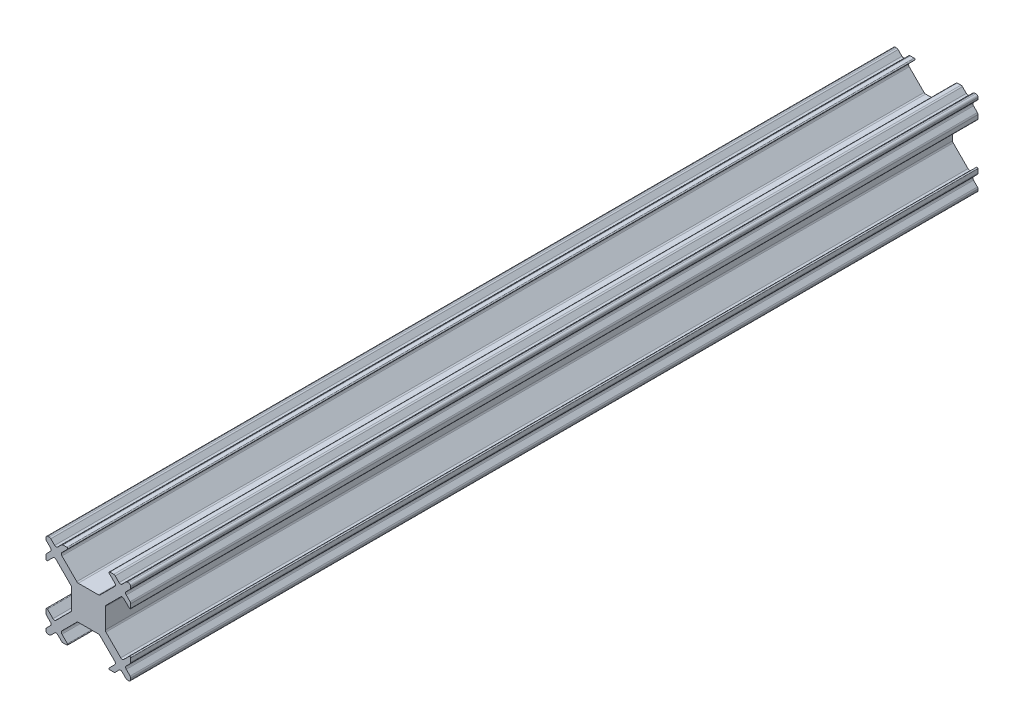
from build123d import *

# Parameters (mm, degrees)
BOSS_EXTRUDE1_DEPTH = 100


with BuildPart() as part:
    # Sketch1 → Boss-Extrude1 (new body)
    with BuildSketch(Plane.XY):
        with BuildLine():
            Line((-26.434620061, 28.496491655), (-25.979594809, 28.951516907))
            ThreePointArc((-25.979594809, 28.951516907), (-25.906371503, 29.128293603), (-25.979594808, 29.305070299))
            Line((-25.979594808, 29.305070299), (-26.43462006, 29.760095551))
            ThreePointArc((-26.43462006, 29.760095551), (-26.488813248, 29.841201388), (-26.507843365, 29.936872247))
            Line((-26.507843365, 29.936872247), (-26.507843365, 30.078293605))
            ThreePointArc((-26.507843365, 30.078293605), (-26.43462006, 30.255070299), (-26.257843366, 30.328293604))
            Line((-26.257843366, 30.328293604), (-26.11642201, 30.328293604))
            ThreePointArc((-26.11642201, 30.328293604), (-26.020751153, 30.309263487), (-25.939645316, 30.255070299))
            Line((-25.939645316, 30.255070299), (-25.484620061, 29.800045045))
            ThreePointArc((-25.484620061, 29.800045045), (-25.307843366, 29.72682174), (-25.131066671, 29.800045045))
            Line((-25.131066671, 29.800045045), (-24.676041418, 30.255070298))
            ThreePointArc((-24.676041418, 30.255070298), (-24.594935581, 30.309263487), (-24.499264722, 30.328293604))
            Line((-24.499264722, 30.328293604), (-24.042157942, 30.328293604))
            ThreePointArc((-24.042157942, 30.328293604), (-23.949769989, 30.266561947), (-23.971447265, 30.157582926))
            Line((-23.971447265, 30.157582926), (-24.623959891, 29.505070299))
            ThreePointArc((-24.623959891, 29.505070299), (-24.697183196, 29.328293604), (-24.623959891, 29.15151691))
            Line((-24.623959891, 29.15151691), (-22.873959891, 27.401516909))
            ThreePointArc((-22.873959891, 27.401516909), (-22.792854054, 27.347323722), (-22.697183196, 27.328293605))
            Line((-22.697183196, 27.328293605), (-20.318503539, 27.328293605))
            ThreePointArc((-20.318503539, 27.328293605), (-20.222832681, 27.347323722), (-20.141726844, 27.401516909))
            Line((-20.141726844, 27.401516909), (-18.391726844, 29.15151691))
            ThreePointArc((-18.391726844, 29.15151691), (-18.318503539, 29.328293604), (-18.391726844, 29.505070299))
            Line((-18.391726844, 29.505070299), (-19.04423947, 30.157582926))
            ThreePointArc((-19.04423947, 30.157582926), (-19.065916745, 30.266561947), (-18.973528793, 30.328293604))
            Line((-18.973528793, 30.328293604), (-18.516422013, 30.328293604))
            ThreePointArc((-18.516422013, 30.328293604), (-18.420751155, 30.309263487), (-18.339645319, 30.2550703))
            Line((-18.339645319, 30.2550703), (-17.884620064, 29.800045045))
            ThreePointArc((-17.884620064, 29.800045045), (-17.707843369, 29.72682174), (-17.531066674, 29.800045045))
            Line((-17.531066674, 29.800045045), (-17.07604142, 30.2550703))
            ThreePointArc((-17.07604142, 30.2550703), (-16.994935583, 30.309263487), (-16.899264725, 30.328293604))
            Line((-16.899264725, 30.328293604), (-16.75784337, 30.328293604))
            ThreePointArc((-16.75784337, 30.328293604), (-16.581066675, 30.255070299), (-16.507843371, 30.078293605))
            Line((-16.507843371, 30.078293605), (-16.507843371, 29.936872247))
            ThreePointArc((-16.507843371, 29.936872247), (-16.526873488, 29.841201389), (-16.581066675, 29.760095552))
            Line((-16.581066675, 29.760095552), (-17.036091927, 29.3050703))
            ThreePointArc((-17.036091927, 29.3050703), (-17.109315232, 29.128293603), (-17.036091926, 28.951516907))
            Line((-17.036091926, 28.951516907), (-16.581066674, 28.496491655))
            ThreePointArc((-16.581066674, 28.496491655), (-16.526873486, 28.415385818), (-16.507843369, 28.31971496))
            Line((-16.507843369, 28.31971496), (-16.507843369, 27.862608178))
            ThreePointArc((-16.507843369, 27.862608178), (-16.569575025, 27.770220231), (-16.678554041, 27.791897499))
            Line((-16.678554041, 27.791897499), (-17.331066668, 28.444410126))
            ThreePointArc((-17.331066668, 28.444410126), (-17.507843364, 28.517633431), (-17.68462006, 28.444410125))
            Line((-17.68462006, 28.444410125), (-19.434620061, 26.694410125))
            ThreePointArc((-19.434620061, 26.694410125), (-19.488813248, 26.613304288), (-19.507843364, 26.51763343))
            Line((-19.507843364, 26.51763343), (-19.507843364, 24.138953775))
            ThreePointArc((-19.507843364, 24.138953775), (-19.488813247, 24.043282917), (-19.434620059, 23.962177079))
            Line((-19.434620059, 23.962177079), (-17.684620059, 22.212177079))
            ThreePointArc((-17.684620059, 22.212177079), (-17.507843363, 22.138953773), (-17.331066666, 22.212177077))
            Line((-17.331066666, 22.212177077), (-16.67855404, 22.864689704))
            ThreePointArc((-16.67855404, 22.864689704), (-16.569575019, 22.886366979), (-16.507843363, 22.793979027))
            Line((-16.507843363, 22.793979027), (-16.507843363, 22.336872245))
            ThreePointArc((-16.507843363, 22.336872245), (-16.52687348, 22.241201387), (-16.581066668, 22.16009555))
            Line((-16.581066668, 22.16009555), (-17.036091921, 21.705070296))
            ThreePointArc((-17.036091921, 21.705070296), (-17.109315225, 21.528293601), (-17.036091921, 21.351516906))
            Line((-17.036091921, 21.351516906), (-16.581066669, 20.896491654))
            ThreePointArc((-16.581066669, 20.896491654), (-16.526873481, 20.815385817), (-16.507843364, 20.719714959))
            Line((-16.507843364, 20.719714959), (-16.507843364, 20.578293601))
            ThreePointArc((-16.507843364, 20.578293601), (-16.581066669, 20.401516906), (-16.757843364, 20.328293601))
            Line((-16.757843364, 20.328293601), (-16.89926472, 20.328293601))
            ThreePointArc((-16.89926472, 20.328293601), (-16.994935578, 20.347323718), (-17.076041415, 20.401516905))
            Line((-17.076041415, 20.401516905), (-17.53106667, 20.85654216))
            ThreePointArc((-17.53106667, 20.85654216), (-17.707843365, 20.929765464), (-17.88462006, 20.85654216))
            Line((-17.88462006, 20.85654216), (-18.339645314, 20.401516905))
            ThreePointArc((-18.339645314, 20.401516905), (-18.420751151, 20.347323718), (-18.516422009, 20.328293601))
            Line((-18.516422009, 20.328293601), (-18.973528789, 20.328293601))
            ThreePointArc((-18.973528789, 20.328293601), (-19.065916743, 20.390025258), (-19.044239468, 20.499004281))
            Line((-19.044239468, 20.499004281), (-18.391726841, 21.151516907))
            ThreePointArc((-18.391726841, 21.151516907), (-18.318503536, 21.328293602), (-18.391726841, 21.505070297))
            Line((-18.391726841, 21.505070297), (-20.141726841, 23.255070297))
            ThreePointArc((-20.141726841, 23.255070297), (-20.222832678, 23.309263485), (-20.318503536, 23.328293602))
            Line((-20.318503536, 23.328293602), (-22.697183193, 23.328293602))
            ThreePointArc((-22.697183193, 23.328293602), (-22.792854051, 23.309263485), (-22.873959889, 23.255070297))
            Line((-22.873959889, 23.255070297), (-24.623959889, 21.505070297))
            ThreePointArc((-24.623959889, 21.505070297), (-24.697183193, 21.328293602), (-24.623959889, 21.151516907))
            Line((-24.623959889, 21.151516907), (-23.971447262, 20.499004281))
            ThreePointArc((-23.971447262, 20.499004281), (-23.949769986, 20.390025258), (-24.042157941, 20.328293601))
            Line((-24.042157941, 20.328293601), (-24.49926472, 20.328293601))
            ThreePointArc((-24.49926472, 20.328293601), (-24.594935579, 20.347323718), (-24.676041417, 20.401516907))
            Line((-24.676041417, 20.401516907), (-25.131066671, 20.85654216))
            ThreePointArc((-25.131066671, 20.85654216), (-25.307843365, 20.929765464), (-25.48462006, 20.85654216))
            Line((-25.48462006, 20.85654216), (-25.939645315, 20.401516906))
            ThreePointArc((-25.939645315, 20.401516906), (-26.020751152, 20.347323718), (-26.11642201, 20.328293601))
            Line((-26.11642201, 20.328293601), (-26.257843366, 20.328293601))
            ThreePointArc((-26.257843366, 20.328293601), (-26.434620061, 20.401516906), (-26.507843366, 20.578293601))
            Line((-26.507843366, 20.578293601), (-26.507843366, 20.719714959))
            ThreePointArc((-26.507843366, 20.719714959), (-26.488813249, 20.815385817), (-26.434620061, 20.896491655))
            Line((-26.434620061, 20.896491655), (-25.979594809, 21.351516907))
            ThreePointArc((-25.979594809, 21.351516907), (-25.906371505, 21.528293602), (-25.979594809, 21.705070297))
            Line((-25.979594809, 21.705070297), (-26.434620063, 22.16009555))
            ThreePointArc((-26.434620063, 22.16009555), (-26.48881325, 22.241201387), (-26.507843367, 22.336872245))
            Line((-26.507843367, 22.336872245), (-26.507843367, 22.793979027))
            ThreePointArc((-26.507843367, 22.793979027), (-26.446111711, 22.88636698), (-26.337132691, 22.864689705))
            Line((-26.337132691, 22.864689705), (-25.684620064, 22.212177078))
            ThreePointArc((-25.684620064, 22.212177078), (-25.507843369, 22.138953774), (-25.331066674, 22.212177078))
            Line((-25.331066674, 22.212177078), (-23.581066674, 23.962177078))
            ThreePointArc((-23.581066674, 23.962177078), (-23.526873485, 24.043282916), (-23.507843368, 24.138953775))
            Line((-23.507843368, 24.138953775), (-23.507843368, 26.51763343))
            ThreePointArc((-23.507843368, 26.51763343), (-23.526873484, 26.613304288), (-23.581066672, 26.694410125))
            Line((-23.581066672, 26.694410125), (-25.331066672, 28.444410125))
            ThreePointArc((-25.331066672, 28.444410125), (-25.507843367, 28.51763343), (-25.684620062, 28.444410125))
            Line((-25.684620062, 28.444410125), (-26.337132689, 27.791897498))
            ThreePointArc((-26.337132689, 27.791897498), (-26.44611171, 27.770220225), (-26.507843366, 27.862608178))
            Line((-26.507843366, 27.862608178), (-26.507843366, 28.31971496))
            ThreePointArc((-26.507843366, 28.31971496), (-26.488813249, 28.415385818), (-26.434620061, 28.496491655))
        make_face()
    extrude(amount=BOSS_EXTRUDE1_DEPTH)


solid = part.part
